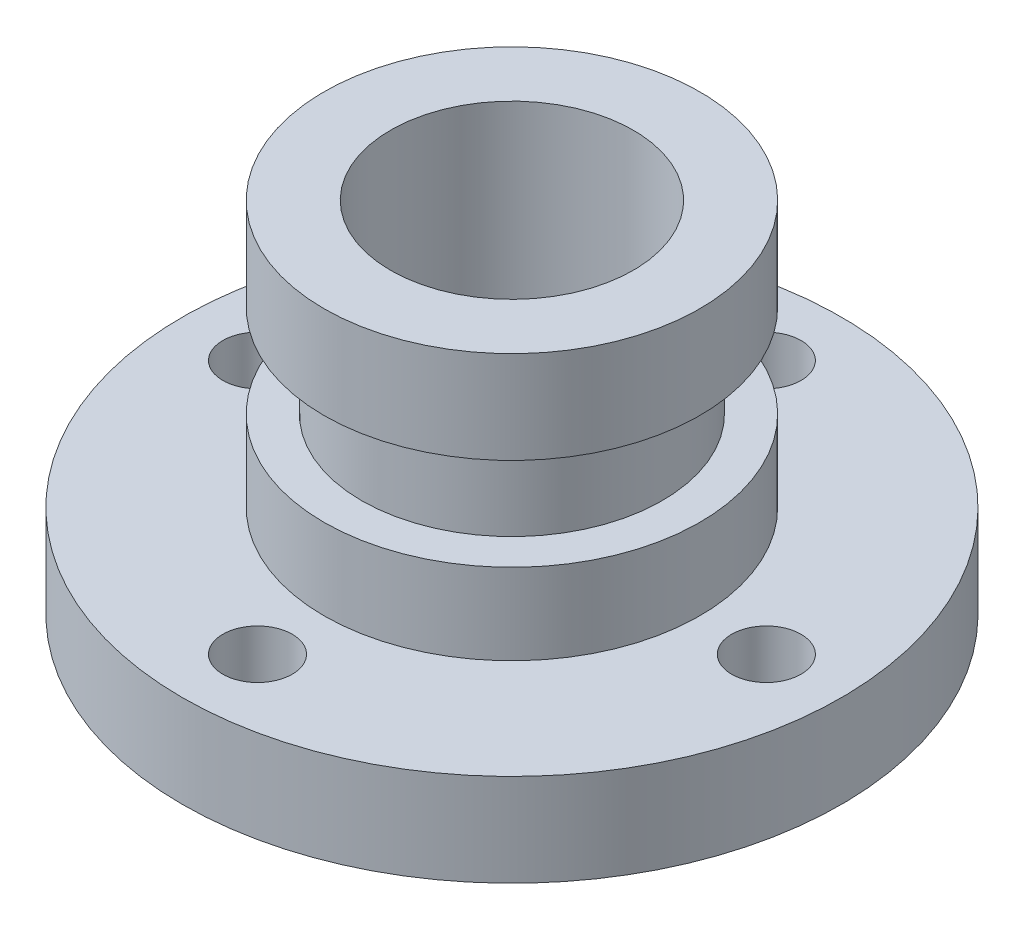
from build123d import *

# Parameters (mm, degrees)
SKETCH_6_R               = 6
CUT_EXTRUDE_2_DEPTH      = 63
PATTERN_CIRCULAR_1_COUNT = 4


with BuildPart() as part:
    # 스케치2 → 회전1 (revolve)
    with BuildSketch(Plane.XY):
        Polygon((0, 0), (57, 0), (57, 16), (32.5, 16), (32.5, 30), (26, 30), (26, 46), (32.5, 46), (32.5, 62), (0, 62), align=None)
    revolve(axis=Axis((0, 81.32, 0), (0, -1, 0)))

    # 스케치5 → 컷-회전1 (revolve, cut)
    with BuildSketch(Plane.XY):
        Polygon((0, 0), (15, 0), (15, 21), (21, 27), (21, 62), (0, 62), align=None)
    revolve(axis=Axis((0, 62, 0), (0, -1, 0)), mode=Mode.SUBTRACT)

    # 스케치6 → 컷-돌출2 (cut, through all)
    with BuildSketch(Plane(origin=(0, 0, 0), x_dir=(1, 0, 0), z_dir=(0, 1, 0))):
        with Locations((0, 44)):
            Circle(SKETCH_6_R)
    cut_extrude_2 = extrude(amount=CUT_EXTRUDE_2_DEPTH, mode=Mode.SUBTRACT)

    # 원형 패턴1: 컷-돌출2 ×4 about axis
    pattern_circular_1_axis = Axis((0, 0, 0), (0, 1, 0))
    for i in range(1, PATTERN_CIRCULAR_1_COUNT):
        add(cut_extrude_2.rotate(pattern_circular_1_axis, i * 360 / PATTERN_CIRCULAR_1_COUNT), mode=Mode.SUBTRACT)


solid = part.part
